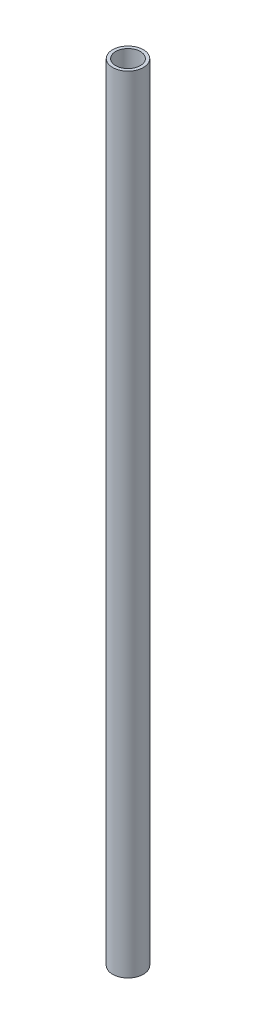
from build123d import *

# Parameters (mm, degrees)
SKETCH_1_R      = 10
EXTRUDE_1_DEPTH = 510
SHELL_1_T       = -2


with BuildPart() as part:
    # 草图1 → 凸台-拉伸1 (new body)
    with BuildSketch(Plane(origin=(0, 0, 0), x_dir=(1, 0, 0), z_dir=(0, 1, 0))):
        with Locations(Location((0, 0, 0), (0, 0, 270))):
            Circle(SKETCH_1_R)
    extrude(amount=EXTRUDE_1_DEPTH)

    # 抽壳1
    shell_1_openings = [part.faces().sort_by_distance(p)[0] for p in [
        (0, 510, 0),
    ]]
    offset(amount=SHELL_1_T, openings=shell_1_openings, kind=Kind.INTERSECTION)


solid = part.part
